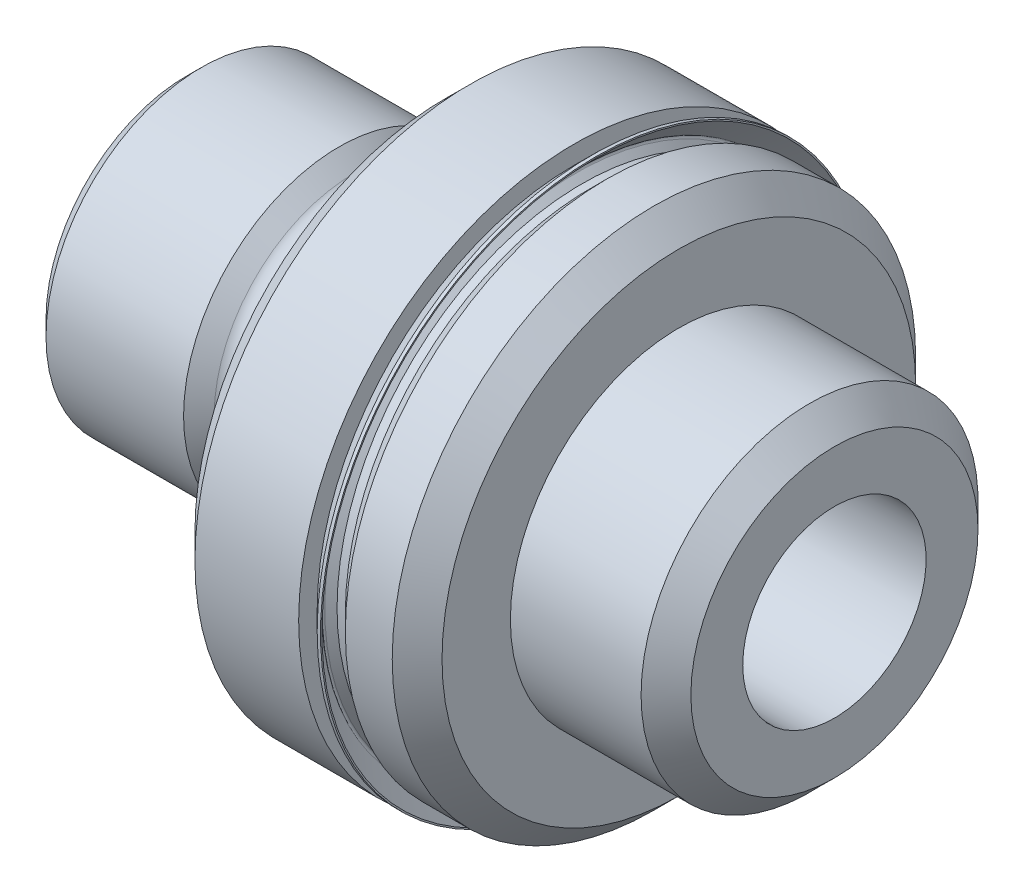
from build123d import *

# Parameters (mm, degrees)
HOLE1_D           = 11.2268
HOLE1_CSINK_D     = 12.7508
HOLE1_CSINK_ANGLE = 90


with BuildPart() as part:
    # Sketch1 → Revolve1 (revolve)
    with BuildSketch(Plane.XY):
        with BuildLine():
            Line((0, 0), (0, 8.58901))
            Line((0, 8.58901), (0.93599, 9.525))
            Line((0.93599, 9.525), (9.35648951, 9.525))
            Line((9.35648951, 9.525), (10.295571935, 8.59395034))
            ThreePointArc((10.295571935, 8.59395034), (10.624110429, 8.375955547), (11.0109, 8.29945))
            Line((11.0109, 8.29945), (12.446, 8.29945))
            ThreePointArc((12.446, 8.29945), (13.16442049, 8.59702951), (13.462, 9.31545))
            Line((13.462, 9.31545), (13.462, 9.49325))
            Line((13.462, 9.49325), (15.8496, 9.49325))
            Line((15.8496, 9.49325), (15.8496, 0))
            Line((15.8496, 0), (0, 0))
        make_face()
    revolve(axis=Axis((15.8496, 0, 0), (-1, 0, 0)))

    # Sketch2 → Revolve2 (revolve)
    with BuildSketch(Plane.XY):
        Polygon((15.8496, 0), (15.8496, 15.32255), (17.3736, 16.84655), (23.7236, 16.84655), (23.7236, 15.00505), (24.7396, 15.00505), (25.7556, 16.02105), (28.6258, 16.02105), (30.1498, 14.49705), (30.1498, 0), align=None)
    revolve(axis=Axis((30.1498, 0, 0), (-1, 0, 0)))

    # Sketch3 → Revolve3 (revolve)
    with BuildSketch(Plane.XY):
        Polygon((30.1498, 0), (30.1498, 10.3124), (38.1508, 10.3124), (39.6748, 8.7884), (39.6748, 0), align=None)
    revolve(axis=Axis((39.6748, 0, 0), (-1, 0, 0)))

    # Hole1 (through all)
    with Locations(Plane.ZY):
        with Locations((0, 0)):
            CounterSinkHole(HOLE1_D / 2, HOLE1_CSINK_D / 2, counter_sink_angle=HOLE1_CSINK_ANGLE)

    # Sketch6 → Revolve4 (revolve)
    with BuildSketch(Plane.XY):
        with BuildLine():
            Line((23.7236, 14.75105), (24.7396, 14.75105))
            Line((24.7396, 14.75105), (24.7396, 15.00505))
            Line((24.7396, 15.00505), (24.2316, 15.00505))
            Line((24.2316, 15.00505), (23.856982072, 15.379667928))
            ThreePointArc((23.856982072, 15.379667928), (23.819784633, 15.46947049), (23.856982072, 15.559273051))
            Line((23.856982072, 15.559273051), (25.060090825, 16.762381804))
            Line((25.060090825, 16.762381804), (25.060090825, 16.84655))
            Line((25.060090825, 16.84655), (24.856890825, 16.84655))
            Line((24.856890825, 16.84655), (23.7236, 15.713259175))
            Line((23.7236, 15.713259175), (23.7236, 14.75105))
        make_face()
    revolve(axis=Axis((24.7396, 0, 0), (-1, 0, 0)))


solid = part.part
